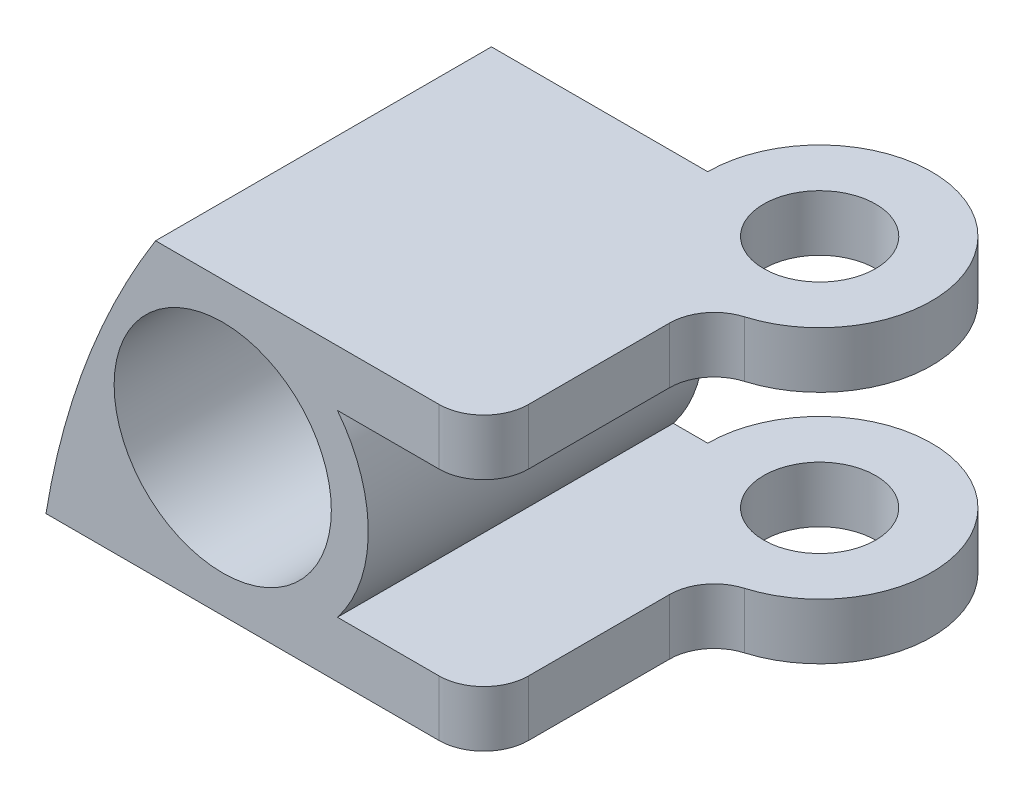
from build123d import *

# Parameters (mm, degrees)
SKETCH2_R           = 6.1595
BOSS_EXTRUDE1_DEPTH = 25.4
SKETCH3_R           = 3.175
CUT_EXTRUDE1_DEPTH  = 25.4
CUT_EXTRUDE2_DEPTH  = 17.51
SKETCH7_R           = 6.35
SKETCH7_R_2         = 3.175
BOSS_EXTRUDE2_DEPTH = 3.175
SKETCH8_R           = 6.35
SKETCH8_R_2         = 3.175
BOSS_EXTRUDE3_DEPTH = 3.175
FILLET1_R           = 2.54
FILLET2_R           = 2.54


with BuildPart() as part:
    # Sketch2 → Boss-Extrude1 (new body)
    with BuildSketch(Plane.XY):
        with BuildLine():
            Line((-37.667011981, 23.60082008), (-13.401813639, 23.60082008))
            Line((-13.401813639, 23.60082008), (-13.401813639, 20.42582008))
            Line((-13.401813639, 20.42582008), (-27.350622089, 20.42582008))
            ThreePointArc((-27.350622089, 20.42582008), (-25.602435825, 15.34582008), (-27.350622089, 10.26582008))
            Line((-27.350622089, 10.26582008), (-13.401813639, 10.26582008))
            Line((-13.401813639, 10.26582008), (-13.401813639, 7.09082008))
            Line((-13.401813639, 7.09082008), (-43.880779056, 7.09082008))
            ThreePointArc((-43.880779056, 7.09082008), (-41.601148791, 15.657168302), (-37.667011981, 23.60082008))
        make_face()
        with Locations((-33.857435825, 15.34582008)):
            Circle(SKETCH2_R, mode=Mode.SUBTRACT)
    extrude(amount=BOSS_EXTRUDE1_DEPTH)

    # Sketch3 → Cut-Extrude1 (cut)
    with BuildSketch(Plane(origin=(0, 23.60082008, 0), x_dir=(1, 0, 0), z_dir=(0, 1, 0))):
        with Locations((-19.05, -6.35)):
            Circle(SKETCH3_R)
    extrude(amount=-CUT_EXTRUDE1_DEPTH, mode=Mode.SUBTRACT)

    # Sketch6 → Cut-Extrude2 (cut, through all)
    with BuildSketch(Plane(origin=(0, 23.60082008, 0), x_dir=(1, 0, 0), z_dir=(0, 1, 0))):
        with BuildLine():
            Line((-40.64, 0), (-46.99, 0))
            ThreePointArc((-46.99, 0), (-51.480128061, -10.840128061), (-40.64, -6.35))
            Line((-40.64, -6.35), (-25.4, -6.35))
            ThreePointArc((-25.4, -6.35), (-14.559871939, -1.859871939), (-19.05, -12.7))
            Line((-19.05, -12.7), (-19.05, -25.4))
            Line((-19.05, -25.4), (-13.401813639, -25.4))
            Line((-13.401813639, -25.4), (-10.329666698, -21.085123092))
            Line((-10.329666698, -21.085123092), (-9.028029261, 2.468316234))
            Line((-9.028029261, 2.468316234), (-25.4, 3.088143584))
            Line((-25.4, 3.088143584), (-40.64, 0))
        make_face()
    extrude(amount=-CUT_EXTRUDE2_DEPTH, mode=Mode.SUBTRACT)

    # Sketch7 → Boss-Extrude2 (add)
    with BuildSketch(Plane(origin=(0, 23.60082008, 0), x_dir=(1, 0, 0), z_dir=(0, 1, 0))):
        with Locations((-19.05, -6.35)):
            Circle(SKETCH7_R)
        with Locations((-19.05, -6.35)):
            Circle(SKETCH7_R_2, mode=Mode.SUBTRACT)
    extrude(amount=-BOSS_EXTRUDE2_DEPTH)

    # Sketch8 → Boss-Extrude3 (add)
    with BuildSketch(Plane.XZ.offset(-7.09082008)):
        with Locations((-19.05, 6.35)):
            Circle(SKETCH8_R)
        with Locations((-19.05, 6.35)):
            Circle(SKETCH8_R_2, mode=Mode.SUBTRACT)
    extrude(amount=-BOSS_EXTRUDE3_DEPTH)

    # Fillet1
    fillet1_edges = [part.edges().sort_by_distance(p)[0] for p in [
        (-19.05, 22.01332008, 12.7),
        (-19.05, 8.67832008, 12.7),
    ]]
    fillet(fillet1_edges, radius=FILLET1_R)

    # Fillet2
    fillet2_edges = [part.edges().sort_by_distance(p)[0] for p in [
        (-19.05, 22.01332008, 25.4),
        (-19.05, 8.67832008, 25.4),
    ]]
    fillet(fillet2_edges, radius=FILLET2_R)


solid = part.part
